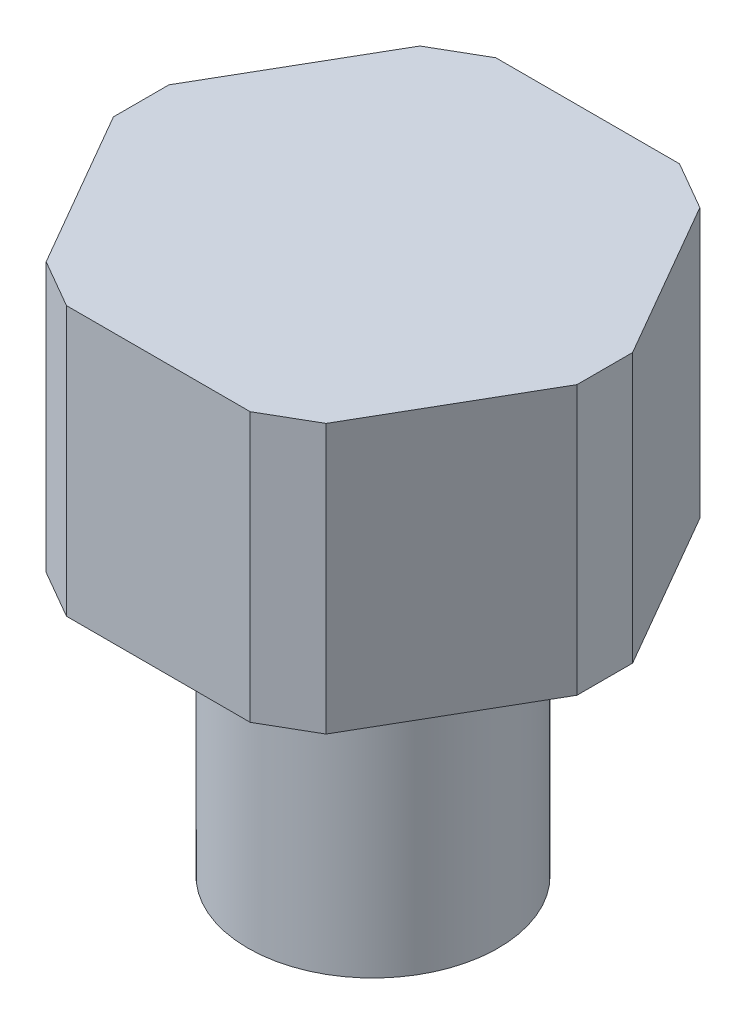
from build123d import *

# Parameters (mm, degrees)
SKETCH1_R           = 5.55625
BOSS_EXTRUDE1_DEPTH = 12.7
BOSS_EXTRUDE2_DEPTH = 11.938


with BuildPart() as part:
    # Sketch1 → Boss-Extrude1 (new body)
    with BuildSketch(Plane(origin=(0, 0, 0), x_dir=(1, 0, 0), z_dir=(0, 1, 0))):
        Circle(SKETCH1_R)
    extrude(amount=BOSS_EXTRUDE1_DEPTH)

    # Sketch3 → Boss-Extrude2 (add)
    with BuildSketch(Plane(origin=(0, 12.7, 0), x_dir=(1, 0, 0), z_dir=(0, 1, 0))):
        Polygon((-10.287, 1.232393343), (-10.287, -1.232393343), (-6.210783894, -8.292606741), (-4.076216154, -9.525), (4.076216154, -9.525), (6.210783894, -8.292606741), (10.287, -1.232393343), (10.287, 1.232393343), (6.210783894, 8.292606741), (4.076216154, 9.525), (-4.076216154, 9.525), (-6.210783894, 8.292606741), align=None)
    extrude(amount=BOSS_EXTRUDE2_DEPTH)


solid = part.part
